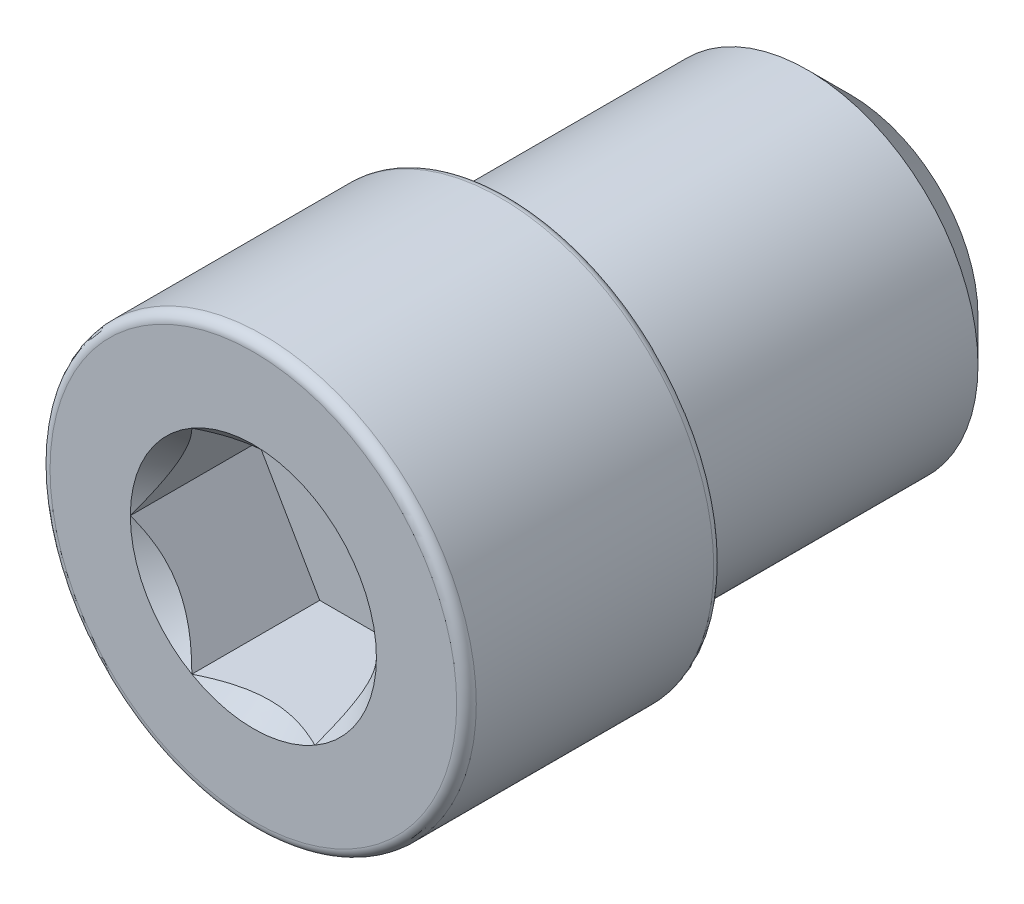
from build123d import *

# Parameters (mm, degrees)
SCHIZZO1_R                   = 4
ESTRUSIONE_ESTRUSIONE1_DEPTH = 8
SMUSSO1_SIZE                 = 1
SCHIZZO6_R                   = 5
ESTRUSIONE_ESTRUSIONE3_DEPTH = 6
TAGLIO_ESTRUSIONE3_DEPTH     = 3
SCHIZZO8_R                   = 2.886751346
TAGLIO_ESTRUSIONE4_DEPTH     = 1
TAGLIO_ESTRUSIONE4_TAPER     = 45
RACCORDO1_R                  = 0.23
RACCORDO2_R                  = 0.2


with BuildPart() as part:
    # Schizzo1 → Estrusione-Estrusione1 (new body)
    with BuildSketch(Plane.XY):
        Circle(SCHIZZO1_R)
    extrude(amount=ESTRUSIONE_ESTRUSIONE1_DEPTH)

    # Smusso1
    smusso1_edges = [part.edges().sort_by_distance(p)[0] for p in [
        (-4, 0, 0),
    ]]
    chamfer(smusso1_edges, length=SMUSSO1_SIZE)

    # Schizzo6 → Estrusione-Estrusione3 (add)
    with BuildSketch(Plane.XY.offset(8)):
        Circle(SCHIZZO6_R)
    extrude(amount=ESTRUSIONE_ESTRUSIONE3_DEPTH)

    # Schizzo7 → Taglio-Estrusione3 (cut)
    with BuildSketch(Plane.XY.offset(14)):
        Polygon((1.443375673, 2.5), (-1.443375673, 2.5), (-2.886751346, 0), (-1.443375673, -2.5), (1.443375673, -2.5), (2.886751346, 0), align=None)
    extrude(amount=-TAGLIO_ESTRUSIONE3_DEPTH, mode=Mode.SUBTRACT)

    # Schizzo8 → Taglio-Estrusione4 (cut)
    with BuildSketch(Plane.XY.offset(14)):
        Circle(SCHIZZO8_R)
    extrude(amount=-TAGLIO_ESTRUSIONE4_DEPTH, taper=TAGLIO_ESTRUSIONE4_TAPER, mode=Mode.SUBTRACT)

    # Raccordo1
    raccordo1_edges = [part.edges().sort_by_distance(p)[0] for p in [
        (-5, 0, 14),
    ]]
    fillet(raccordo1_edges, radius=RACCORDO1_R)

    # Raccordo2
    raccordo2_edges = [part.edges().sort_by_distance(p)[0] for p in [
        (-5, 0, 8),
    ]]
    fillet(raccordo2_edges, radius=RACCORDO2_R)


solid = part.part
